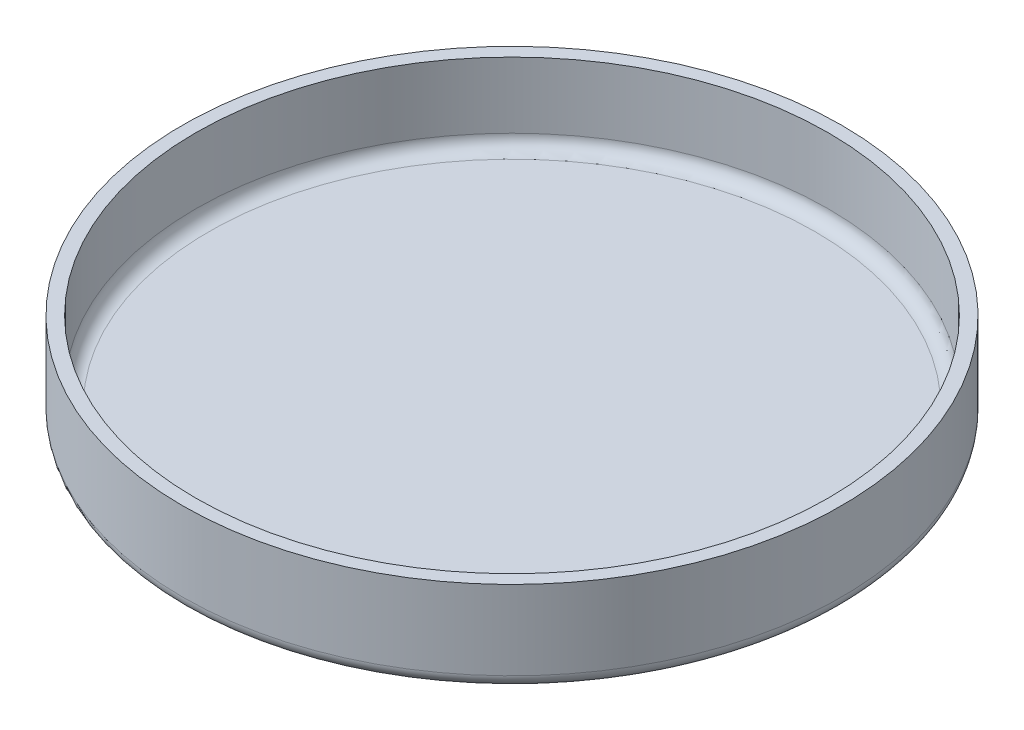
from build123d import *

# Parameters (mm, degrees)
SKETCH1_R           = 25
BOSS_EXTRUDE1_DEPTH = 7
SKETCH2_R           = 24
CUT_EXTRUDE1_DEPTH  = 6
FILLET1_R           = 1


with BuildPart() as part:
    # Sketch1 → Boss-Extrude1 (new body)
    with BuildSketch(Plane(origin=(0, 0, 0), x_dir=(1, 0, 0), z_dir=(0, 1, 0))):
        Circle(SKETCH1_R)
    extrude(amount=BOSS_EXTRUDE1_DEPTH)

    # Sketch2 → Cut-Extrude1 (cut)
    with BuildSketch(Plane(origin=(0, 7, 0), x_dir=(1, 0, 0), z_dir=(0, 1, 0))):
        Circle(SKETCH2_R)
    extrude(amount=-CUT_EXTRUDE1_DEPTH, mode=Mode.SUBTRACT)

    # Fillet1
    fillet1_edges = [part.edges().sort_by_distance(p)[0] for p in [
        (-25, 0, 0),
        (-24, 1, 0),
    ]]
    fillet(fillet1_edges, radius=FILLET1_R)


solid = part.part
